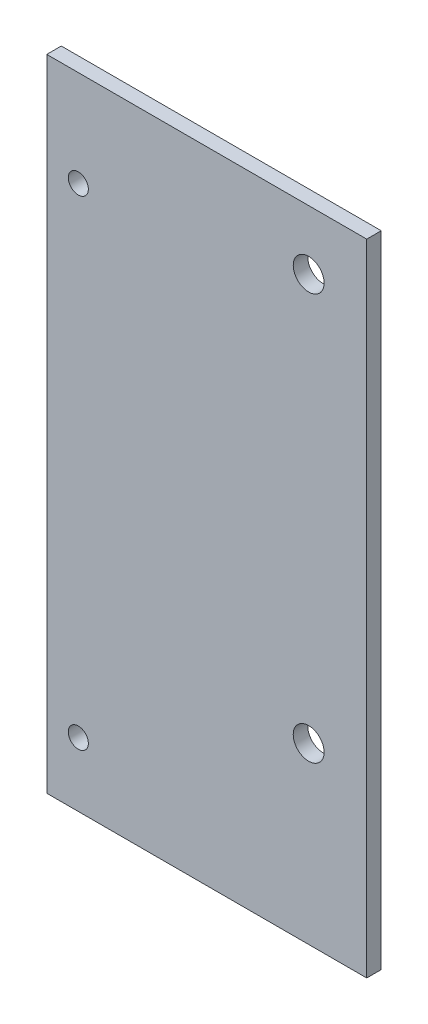
from build123d import *

# Parameters (mm, degrees)
SKETCH1_W           = 70
SKETCH1_H           = 140
BOSS_EXTRUDE1_DEPTH = 3.175
SKETCH2_R           = 2.2
SKETCH2_R_2         = 3.3782
CUT_EXTRUDE1_DEPTH  = 4.175


with BuildPart() as part:
    # Sketch1 → Boss-Extrude1 (new body)
    with BuildSketch(Plane.XY):
        with Locations((35, 70)):
            Rectangle(SKETCH1_W, SKETCH1_H)
    extrude(amount=BOSS_EXTRUDE1_DEPTH)

    # Sketch2 → Cut-Extrude1 (cut, through all)
    with BuildSketch(Plane(origin=(0, 0, 0), x_dir=(-1, 0, 0), z_dir=(0, 0, -1))):
        with Locations((-6.9, 119)):
            Circle(SKETCH2_R)
        with Locations((-57.3, 127)):
            Circle(SKETCH2_R_2)
        with Locations((-57.3, 38.1)):
            Circle(SKETCH2_R_2)
        with Locations((-6.9, 14)):
            Circle(SKETCH2_R)
    extrude(amount=-CUT_EXTRUDE1_DEPTH, mode=Mode.SUBTRACT)


solid = part.part
